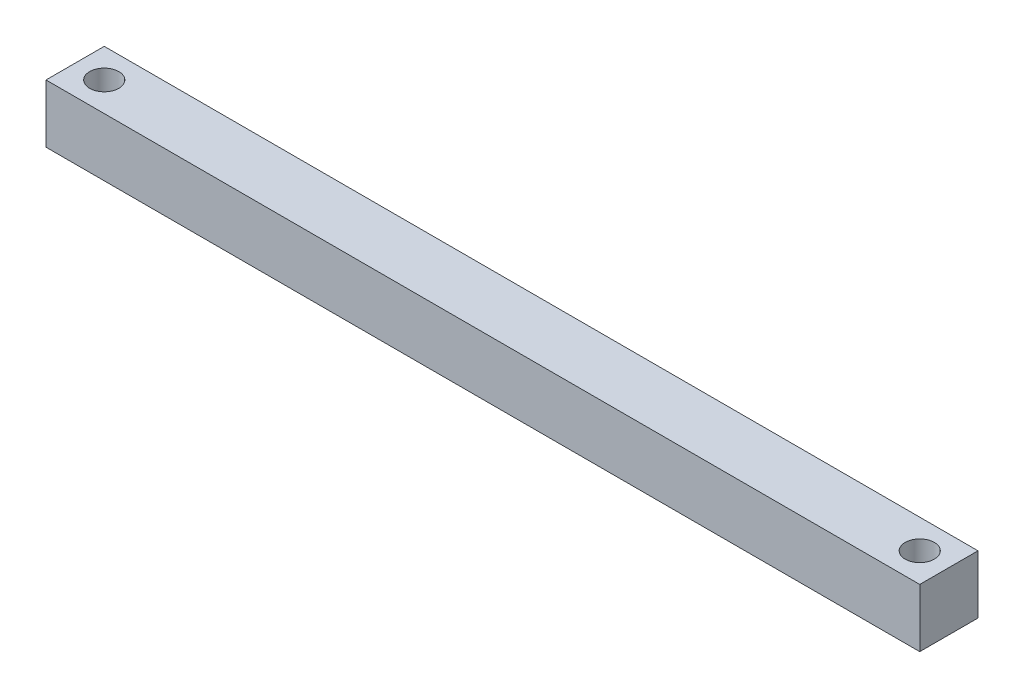
from build123d import *

# Parameters (mm, degrees)
SKETCH1_W           = 25.4
SKETCH1_H           = 25.4
BOSS_EXTRUDE1_DEPTH = 381
SKETCH2_R           = 6.35
CUT_EXTRUDE1_DEPTH  = 26.4


with BuildPart() as part:
    # Sketch1 → Boss-Extrude1 (new body)
    with BuildSketch(Plane(origin=(0, 0, 0), x_dir=(0, 0, -1), z_dir=(1, 0, 0))):
        with Locations((-12.7, 12.7)):
            Rectangle(SKETCH1_W, SKETCH1_H)
    extrude(amount=BOSS_EXTRUDE1_DEPTH)

    # Sketch2 → Cut-Extrude1 (cut, through all)
    with BuildSketch(Plane(origin=(0, 25.4, 0), x_dir=(1, 0, 0), z_dir=(0, 1, 0))):
        with Locations((368.3, -12.7)):
            Circle(SKETCH2_R)
        with Locations((12.7, -12.7)):
            Circle(SKETCH2_R)
    extrude(amount=-CUT_EXTRUDE1_DEPTH, mode=Mode.SUBTRACT)


solid = part.part
